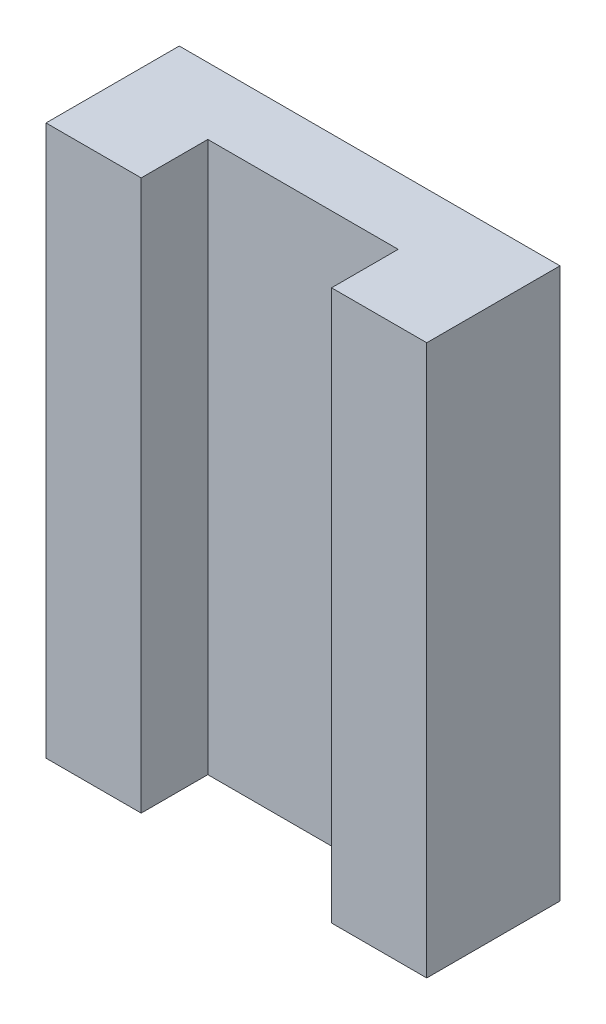
from build123d import *

# Parameters (mm, degrees)
SKETCH_1_W          = 20
SKETCH_1_H          = 28.9
EXTRUDE_1_DEPTH     = 7
CUT_EXTRUDE_1_DEPTH = 30.5
SKETCH_3_R          = 1.5
CUT_EXTRUDE_2_DEPTH = 2.5


with BuildPart() as part:
    # 草图1 → 凸台-拉伸1 (new body)
    with BuildSketch(Plane.XY):
        with Locations((-30.686463881, 21.553540909)):
            Rectangle(SKETCH_1_W, SKETCH_1_H)
    extrude(amount=EXTRUDE_1_DEPTH)

    # 草图2 → 切除-拉伸1 (cut)
    with BuildSketch(Plane(origin=(0, 36.003540909, 0), x_dir=(1, 0, 0), z_dir=(0, 1, 0))):
        Polygon((-30.686463881, -7), (-35.686463881, -7), (-35.686463881, -3.5), (-25.686463881, -3.5), (-25.686463881, -7), align=None)
    extrude(amount=-CUT_EXTRUDE_1_DEPTH, mode=Mode.SUBTRACT)

    # 草图3 → 切除-拉伸2 (cut)
    with BuildSketch(Plane(origin=(0, 0, 0), x_dir=(-1, 0, 0), z_dir=(0, 0, -1))):
        with Locations((23.186463881, 31.003540909)):
            Circle(SKETCH_3_R)
        with Locations((38.186463881, 31.003540909)):
            Circle(SKETCH_3_R)
        with Locations((38.186463881, 12.103540909)):
            Circle(SKETCH_3_R)
        with Locations((23.186463881, 12.103540909)):
            Circle(SKETCH_3_R)
    extrude(amount=-CUT_EXTRUDE_2_DEPTH, mode=Mode.SUBTRACT)


solid = part.part
